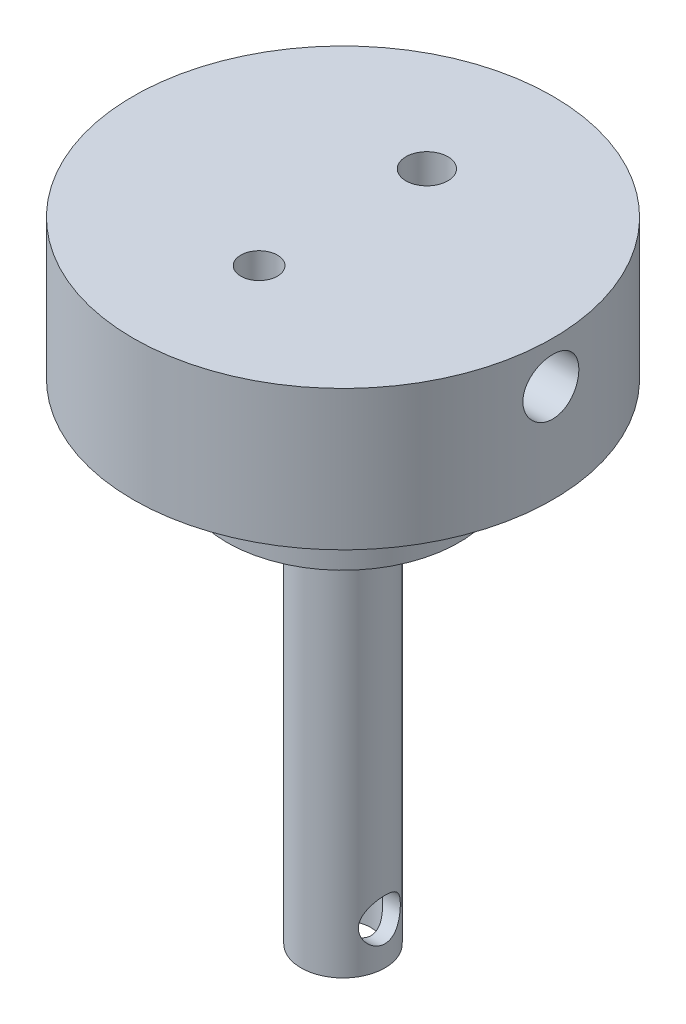
from build123d import *

# Parameters (mm, degrees)
SKETCH1_R           = 7.5
BOSS_EXTRUDE1_DEPTH = 5
SKETCH6_R           = 1
SKETCH12_R          = 4.15
BOSS_EXTRUDE2_DEPTH = 3
SKETCH13_R          = 1.5
BOSS_EXTRUDE3_DEPTH = 14.5
CUT_EXTRUDE5_REACH  = 24.5
SKETCH21_R          = 1
SKETCH22_R          = 0.75
CUT_EXTRUDE6_DEPTH  = 18.5000001
SKETCH23_R          = 0.654937639
SKETCH23_R_2        = 0.75
CUT_EXTRUDE7_DEPTH  = 10


with BuildPart() as part:
    # Sketch1 → Boss-Extrude1 (new body)
    with BuildSketch(Plane(origin=(0, 0, 0), x_dir=(1, 0, 0), z_dir=(0, 1, 0))):
        Circle(SKETCH1_R)
    extrude(amount=BOSS_EXTRUDE1_DEPTH)

    # Cut-Sweep2: sweep along a path in Sketch5
    with BuildLine(Plane.XY) as cut_sweep2_path:
        Line((0, 0), (0, 0.5))
        ThreePointArc((0, 0.5), (0.878679656, 2.621320344), (3, 3.5))
        Line((3, 3.5), (7.5, 3.5))
    # Sketch6 → Cut-Sweep2 (sweep, cut)
    with BuildSketch(Plane(origin=(0, 0, 0), x_dir=(-1, 0, 0), z_dir=(0, -1, 0))):
        Circle(SKETCH6_R)
    sweep(path=cut_sweep2_path.line, mode=Mode.SUBTRACT)

    # Sketch12 → Boss-Extrude2 (add)
    with BuildSketch(Plane(origin=(0, 0, 0), x_dir=(-1, 0, 0), z_dir=(0, -1, 0))):
        Circle(SKETCH12_R)
    extrude(amount=BOSS_EXTRUDE2_DEPTH)

    # Sketch13 → Boss-Extrude3 (add)
    with BuildSketch(Plane.XZ.offset(3)):
        Circle(SKETCH13_R)
    extrude(amount=BOSS_EXTRUDE3_DEPTH)

    # Sketch21 → Cut-Extrude5 (cut, up to next)
    with BuildSketch(Plane(origin=(0, -17.5, 0), x_dir=(-1, 0, 0), z_dir=(0, -1, 0)), mode=Mode.PRIVATE) as cut_extrude5_sk1:
        Circle(SKETCH21_R)
    cut_extrude5_tool1 = extrude(cut_extrude5_sk1.sketch, amount=-CUT_EXTRUDE5_REACH, mode=Mode.PRIVATE) & part.part
    add(cut_extrude5_tool1.solids().sort_by_distance((0, -17.5, 0))[0], mode=Mode.SUBTRACT)

    # Sketch22 → Cut-Extrude6 (cut, through all)
    with BuildSketch(Plane(origin=(10, 0, 0), x_dir=(0, 0, -1), z_dir=(1, 0, 0))):
        with Locations((0, -16)):
            Circle(SKETCH22_R)
    extrude(amount=-CUT_EXTRUDE6_DEPTH, mode=Mode.SUBTRACT)

    # Sketch23 → Cut-Extrude7 (cut)
    with BuildSketch(Plane.XZ.offset(3)):
        with Locations((0, 3)):
            Circle(SKETCH23_R)
        with Locations((0, -3)):
            Circle(SKETCH23_R_2)
    extrude(amount=-CUT_EXTRUDE7_DEPTH, mode=Mode.SUBTRACT)


solid = part.part
